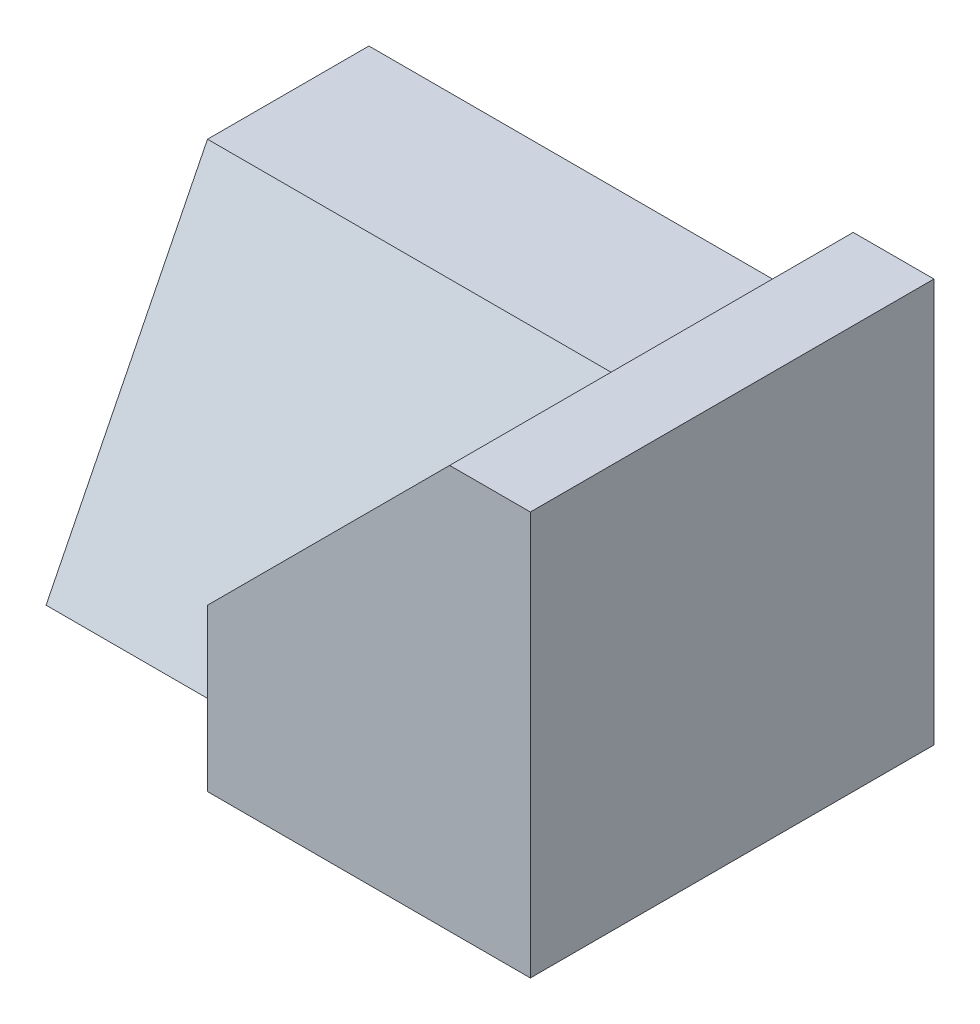
from build123d import *

# Parameters (mm, degrees)
SKETCH1_W           = 70
SKETCH1_H           = 50
BOSS_EXTRUDE1_DEPTH = 50
CUT_EXTRUDE1_DEPTH  = 50
CUT_EXTRUDE2_DEPTH  = 30
BOSS_EXTRUDE2_DEPTH = 30
SKETCH8_W           = 70
SKETCH8_H           = 40
CUT_EXTRUDE7_DEPTH  = 30
SKETCH9_W           = 70
SKETCH9_H           = 50
CUT_EXTRUDE8_DEPTH  = 30


with BuildPart() as part:
    # Sketch1 → Boss-Extrude1 (new body)
    with BuildSketch(Plane.XY):
        with Locations((35, 25)):
            Rectangle(SKETCH1_W, SKETCH1_H)
    extrude(amount=BOSS_EXTRUDE1_DEPTH)

    # Sketch2 → Cut-Extrude1 (cut)
    with BuildSketch(Plane.XY.offset(50)):
        Polygon((0, 40), (50, 40), (60, 50), (0, 50), align=None)
    extrude(amount=-CUT_EXTRUDE1_DEPTH, mode=Mode.SUBTRACT)

    # Sketch3 → Cut-Extrude2 (cut)
    with BuildSketch(Plane.XY.offset(50)):
        Polygon((50, 40), (30, 20), (30, 0), (0, 0), (0, 40), align=None)
    extrude(amount=-CUT_EXTRUDE2_DEPTH, mode=Mode.SUBTRACT)

    # Sketch7 → Boss-Extrude2 (add)
    with BuildSketch(Plane(origin=(0, 16, 32), x_dir=(-1, 0, 0), z_dir=(0, -0.447213595, -0.894427191))):
        Polygon((0, 26.83281573), (-50, 26.83281573), (-30, -17.88854382), (0, -17.88854382), align=None)
    extrude(amount=BOSS_EXTRUDE2_DEPTH)

    # Sketch8 → Cut-Extrude7 (cut)
    with BuildSketch(Plane(origin=(0, 0, 0), x_dir=(-1, 0, 0), z_dir=(0, 0, -1))):
        with Locations((-35, 20)):
            Rectangle(SKETCH8_W, SKETCH8_H)
    extrude(amount=CUT_EXTRUDE7_DEPTH, mode=Mode.SUBTRACT)

    # Sketch9 → Cut-Extrude8 (cut)
    with BuildSketch(Plane.XZ):
        with Locations((35, 25)):
            Rectangle(SKETCH9_W, SKETCH9_H)
    extrude(amount=CUT_EXTRUDE8_DEPTH, mode=Mode.SUBTRACT)


solid = part.part
